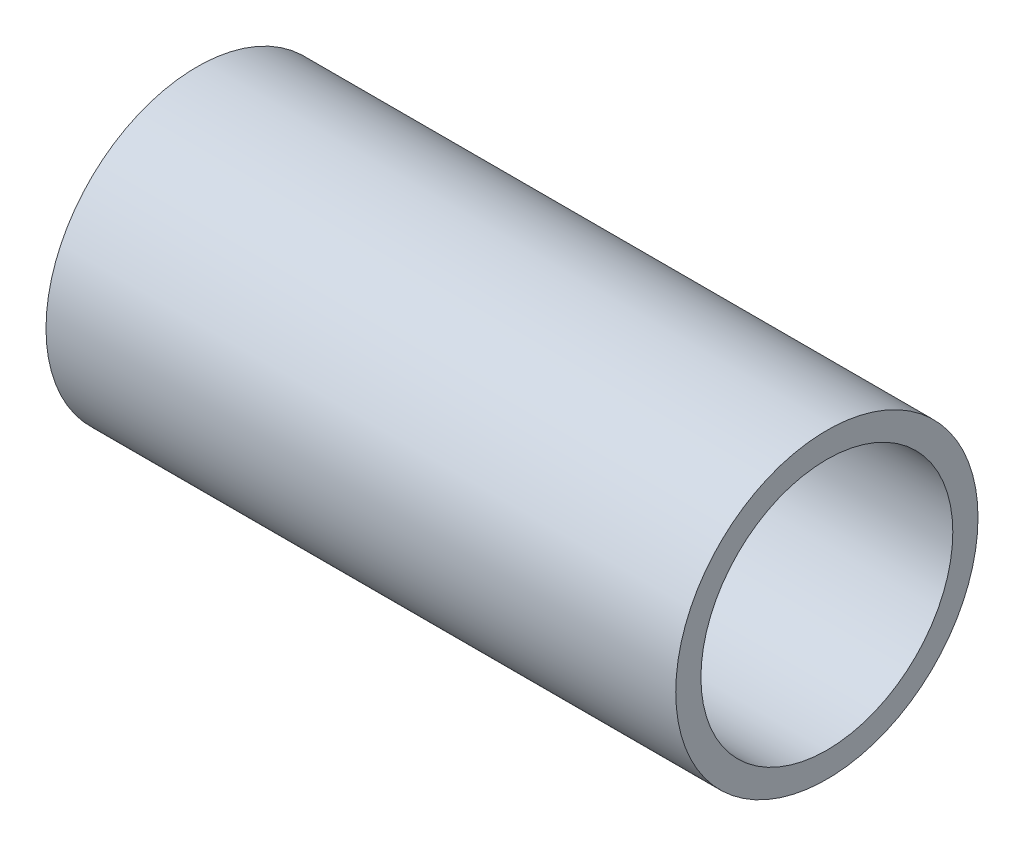
from build123d import *

# Parameters (mm, degrees)
SKIZZE1_W = 25
SKIZZE1_H = 1


with BuildPart() as part:
    # Skizze1 → Rotation1 (revolve)
    with BuildSketch(Plane(origin=(0, 0, 0), x_dir=(1, 0, 0), z_dir=(0, 1, 0))):
        with Locations((12.5, 5.5)):
            Rectangle(SKIZZE1_W, SKIZZE1_H)
    revolve(axis=Axis((0, 0, 0), (1, 0, 0)))


solid = part.part
